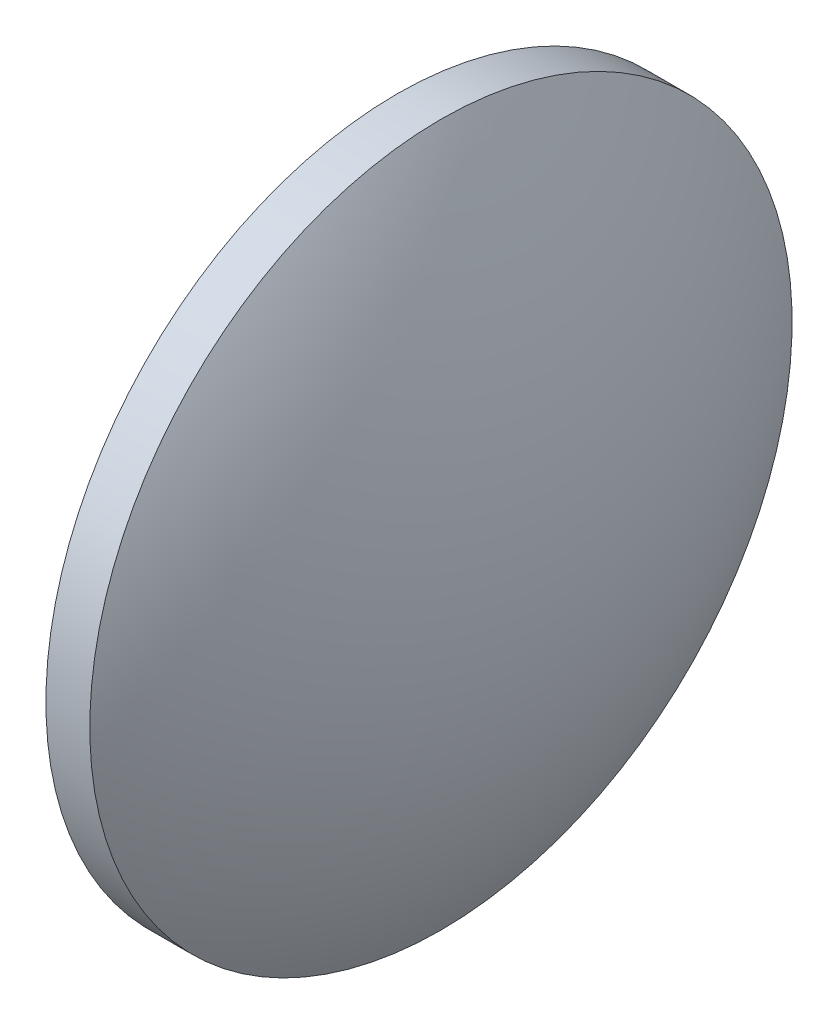
from build123d import *

# Parameters (mm, degrees)
SKETCH_1_ONE_SIDE_W = 2.5
SKETCH_1_ONE_SIDE_H = 20


with BuildPart() as part:
    # 草图1 one side → 旋转1 (revolve)
    with BuildSketch(Plane.XY):
        with Locations((136.154635866, 86.560807911)):
            Rectangle(SKETCH_1_ONE_SIDE_W, SKETCH_1_ONE_SIDE_H)
        with BuildLine():
            Line((129.359635866, 76.560807911), (134.904635866, 76.560807911))
            Line((134.904635866, 76.560807911), (134.904635866, 96.560807911))
            ThreePointArc((134.904635866, 96.560807911), (130.771548112, 86.938030865), (129.359635866, 76.560807911))
        make_face()
        with BuildLine():
            Line((137.404635866, 76.560807911), (142.949635866, 76.560807911))
            ThreePointArc((142.949635866, 76.560807911), (141.537723619, 86.938030865), (137.404635866, 96.560807911))
            Line((137.404635866, 96.560807911), (137.404635866, 76.560807911))
        make_face()
    revolve(axis=Axis((104.108605658, 76.560807911, 0), (1, 0, 0)))


solid = part.part
